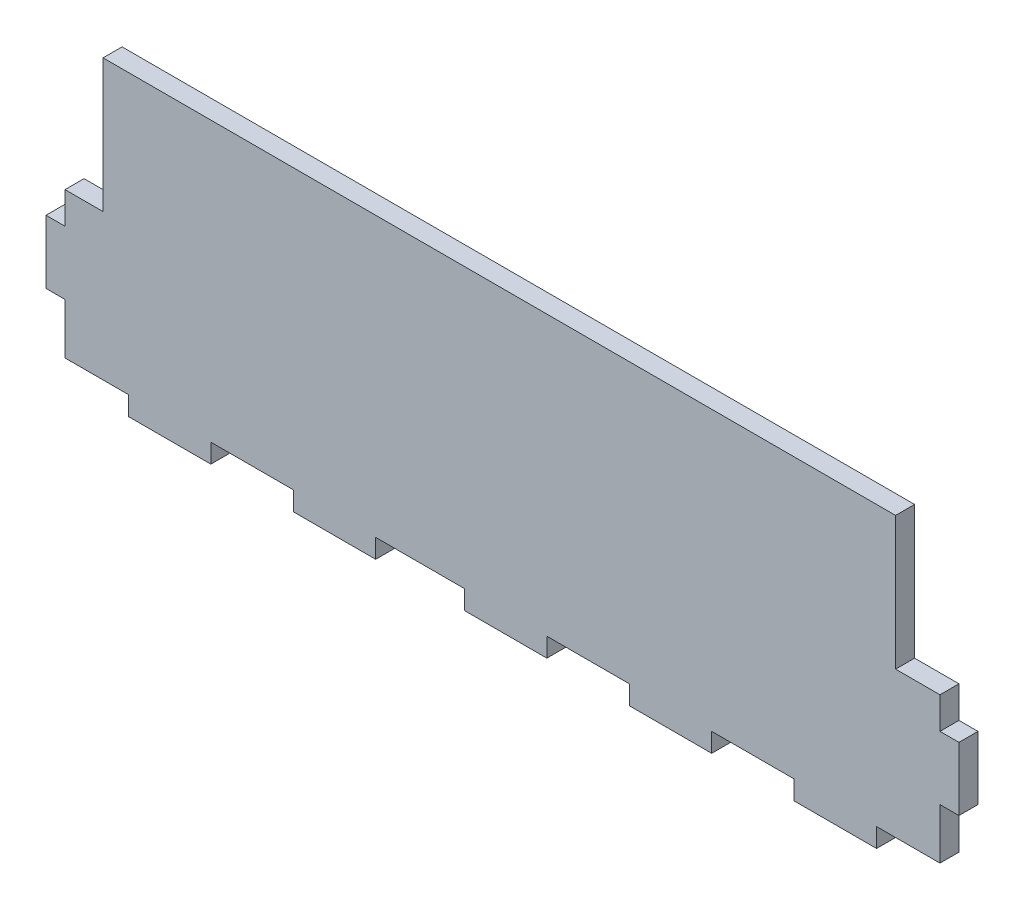
from build123d import *

# Parameters (mm, degrees)
BOSS_EXTRUDE1_DEPTH = 3


with BuildPart() as part:
    # Sketch1 → Boss-Extrude1 (new body)
    with BuildSketch(Plane.XY):
        Polygon((14.633144841, 0), (27.633144841, 0), (27.633144841, -3), (40.633144841, -3), (40.633144841, 0), (54.633144841, 0), (54.633144841, -3), (67.633144841, -3), (67.633144841, 0), (80.633144841, 0), (80.633144841, -3), (93.633144841, -3), (93.633144841, 0), (106.633144841, 0), (106.633144841, -3), (119.633144841, -3), (119.633144841, 0), (125, 0), (129.633144841, 0), (129.633144841, 8), (132.633144841, 8), (132.633144841, 18), (129.633144841, 18), (129.633144841, 23), (122.633144841, 23), (122.633144841, 44), (-2.366855159, 44), (-2.366855159, 23), (-8.366855159, 23), (-8.366855159, 18), (-11.366855159, 18), (-11.366855159, 8), (-8.366855159, 8), (-8.366855159, 0), (0, 0), (1.633144841, 0), (1.633144841, -3), (14.633144841, -3), align=None)
    extrude(amount=BOSS_EXTRUDE1_DEPTH)


solid = part.part
